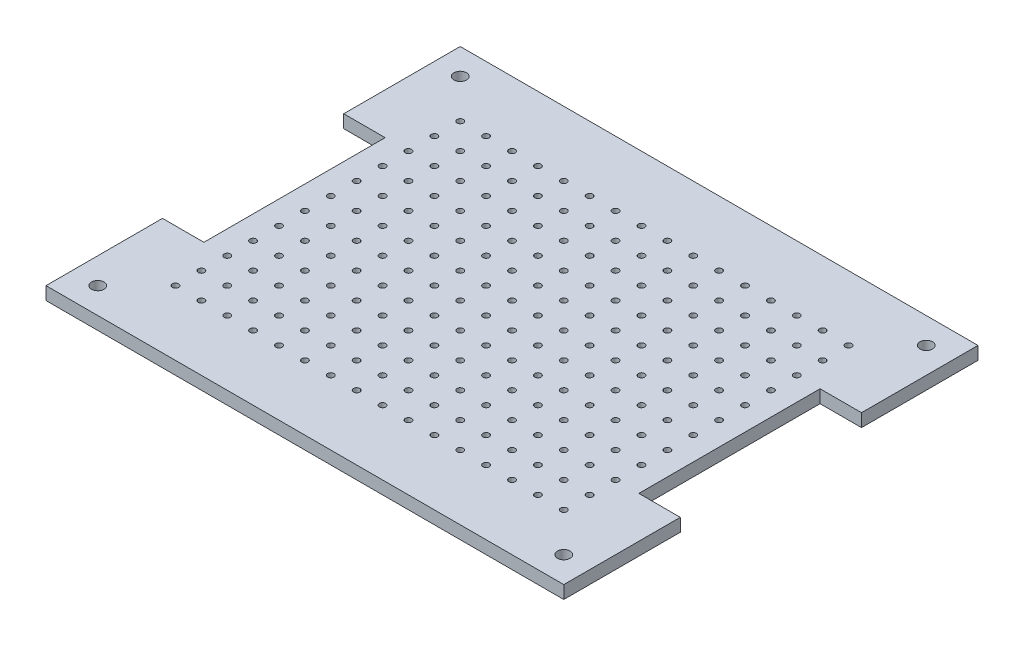
from build123d import *

# Parameters (mm, degrees)
SKETCH1_R           = 1.55
SKETCH1_R_2         = 3.1
BOSS_EXTRUDE1_DEPTH = 6.35


with BuildPart() as part:
    # Sketch1 → Boss-Extrude1 (new body)
    with BuildSketch(Plane(origin=(0, 0, 0), x_dir=(1, 0, 0), z_dir=(0, 1, 0))):
        Polygon((0, 0), (254, 0), (254, 57.15), (233.68, 57.15), (233.68, 146.05), (254, 146.05), (254, 203.2), (0, 203.2), (0, 146.05), (20.32, 146.05), (20.32, 57.15), (0, 57.15), align=None)
        with Locations((31.75, 171.45)):
            Circle(SKETCH1_R, mode=Mode.SUBTRACT)
        with Locations((44.45, 171.45)):
            Circle(SKETCH1_R, mode=Mode.SUBTRACT)
        with Locations((57.15, 171.45)):
            Circle(SKETCH1_R, mode=Mode.SUBTRACT)
        with Locations((69.85, 171.45)):
            Circle(SKETCH1_R, mode=Mode.SUBTRACT)
        with Locations((82.55, 171.45)):
            Circle(SKETCH1_R, mode=Mode.SUBTRACT)
        with Locations((95.25, 171.45)):
            Circle(SKETCH1_R, mode=Mode.SUBTRACT)
        with Locations((107.95, 171.45)):
            Circle(SKETCH1_R, mode=Mode.SUBTRACT)
        with Locations((120.65, 171.45)):
            Circle(SKETCH1_R, mode=Mode.SUBTRACT)
        with Locations((133.35, 171.45)):
            Circle(SKETCH1_R, mode=Mode.SUBTRACT)
        with Locations((146.05, 171.45)):
            Circle(SKETCH1_R, mode=Mode.SUBTRACT)
        with Locations((158.75, 171.45)):
            Circle(SKETCH1_R, mode=Mode.SUBTRACT)
        with Locations((171.45, 171.45)):
            Circle(SKETCH1_R, mode=Mode.SUBTRACT)
        with Locations((184.15, 171.45)):
            Circle(SKETCH1_R, mode=Mode.SUBTRACT)
        with Locations((196.85, 171.45)):
            Circle(SKETCH1_R, mode=Mode.SUBTRACT)
        with Locations((209.55, 171.45)):
            Circle(SKETCH1_R, mode=Mode.SUBTRACT)
        with Locations((222.25, 171.45)):
            Circle(SKETCH1_R, mode=Mode.SUBTRACT)
        with Locations((44.45, 158.75)):
            Circle(SKETCH1_R, mode=Mode.SUBTRACT)
        with Locations((57.15, 158.75)):
            Circle(SKETCH1_R, mode=Mode.SUBTRACT)
        with Locations((69.85, 158.75)):
            Circle(SKETCH1_R, mode=Mode.SUBTRACT)
        with Locations((82.55, 158.75)):
            Circle(SKETCH1_R, mode=Mode.SUBTRACT)
        with Locations((95.25, 158.75)):
            Circle(SKETCH1_R, mode=Mode.SUBTRACT)
        with Locations((107.95, 158.75)):
            Circle(SKETCH1_R, mode=Mode.SUBTRACT)
        with Locations((120.65, 158.75)):
            Circle(SKETCH1_R, mode=Mode.SUBTRACT)
        with Locations((133.35, 158.75)):
            Circle(SKETCH1_R, mode=Mode.SUBTRACT)
        with Locations((146.05, 158.75)):
            Circle(SKETCH1_R, mode=Mode.SUBTRACT)
        with Locations((158.75, 158.75)):
            Circle(SKETCH1_R, mode=Mode.SUBTRACT)
        with Locations((171.45, 158.75)):
            Circle(SKETCH1_R, mode=Mode.SUBTRACT)
        with Locations((184.15, 158.75)):
            Circle(SKETCH1_R, mode=Mode.SUBTRACT)
        with Locations((196.85, 158.75)):
            Circle(SKETCH1_R, mode=Mode.SUBTRACT)
        with Locations((209.55, 158.75)):
            Circle(SKETCH1_R, mode=Mode.SUBTRACT)
        with Locations((222.25, 158.75)):
            Circle(SKETCH1_R, mode=Mode.SUBTRACT)
        with Locations((44.45, 146.05)):
            Circle(SKETCH1_R, mode=Mode.SUBTRACT)
        with Locations((57.15, 146.05)):
            Circle(SKETCH1_R, mode=Mode.SUBTRACT)
        with Locations((69.85, 146.05)):
            Circle(SKETCH1_R, mode=Mode.SUBTRACT)
        with Locations((82.55, 146.05)):
            Circle(SKETCH1_R, mode=Mode.SUBTRACT)
        with Locations((95.25, 146.05)):
            Circle(SKETCH1_R, mode=Mode.SUBTRACT)
        with Locations((107.95, 146.05)):
            Circle(SKETCH1_R, mode=Mode.SUBTRACT)
        with Locations((120.65, 146.05)):
            Circle(SKETCH1_R, mode=Mode.SUBTRACT)
        with Locations((133.35, 146.05)):
            Circle(SKETCH1_R, mode=Mode.SUBTRACT)
        with Locations((146.05, 146.05)):
            Circle(SKETCH1_R, mode=Mode.SUBTRACT)
        with Locations((158.75, 146.05)):
            Circle(SKETCH1_R, mode=Mode.SUBTRACT)
        with Locations((171.45, 146.05)):
            Circle(SKETCH1_R, mode=Mode.SUBTRACT)
        with Locations((184.15, 146.05)):
            Circle(SKETCH1_R, mode=Mode.SUBTRACT)
        with Locations((196.85, 146.05)):
            Circle(SKETCH1_R, mode=Mode.SUBTRACT)
        with Locations((209.55, 146.05)):
            Circle(SKETCH1_R, mode=Mode.SUBTRACT)
        with Locations((222.25, 146.05)):
            Circle(SKETCH1_R, mode=Mode.SUBTRACT)
        with Locations((44.45, 133.35)):
            Circle(SKETCH1_R, mode=Mode.SUBTRACT)
        with Locations((57.15, 133.35)):
            Circle(SKETCH1_R, mode=Mode.SUBTRACT)
        with Locations((69.85, 133.35)):
            Circle(SKETCH1_R, mode=Mode.SUBTRACT)
        with Locations((82.55, 133.35)):
            Circle(SKETCH1_R, mode=Mode.SUBTRACT)
        with Locations((95.25, 133.35)):
            Circle(SKETCH1_R, mode=Mode.SUBTRACT)
        with Locations((107.95, 133.35)):
            Circle(SKETCH1_R, mode=Mode.SUBTRACT)
        with Locations((120.65, 133.35)):
            Circle(SKETCH1_R, mode=Mode.SUBTRACT)
        with Locations((133.35, 133.35)):
            Circle(SKETCH1_R, mode=Mode.SUBTRACT)
        with Locations((146.05, 133.35)):
            Circle(SKETCH1_R, mode=Mode.SUBTRACT)
        with Locations((158.75, 133.35)):
            Circle(SKETCH1_R, mode=Mode.SUBTRACT)
        with Locations((171.45, 133.35)):
            Circle(SKETCH1_R, mode=Mode.SUBTRACT)
        with Locations((184.15, 133.35)):
            Circle(SKETCH1_R, mode=Mode.SUBTRACT)
        with Locations((196.85, 133.35)):
            Circle(SKETCH1_R, mode=Mode.SUBTRACT)
        with Locations((209.55, 133.35)):
            Circle(SKETCH1_R, mode=Mode.SUBTRACT)
        with Locations((222.25, 133.35)):
            Circle(SKETCH1_R, mode=Mode.SUBTRACT)
        with Locations((44.45, 120.65)):
            Circle(SKETCH1_R, mode=Mode.SUBTRACT)
        with Locations((57.15, 120.65)):
            Circle(SKETCH1_R, mode=Mode.SUBTRACT)
        with Locations((69.85, 120.65)):
            Circle(SKETCH1_R, mode=Mode.SUBTRACT)
        with Locations((82.55, 120.65)):
            Circle(SKETCH1_R, mode=Mode.SUBTRACT)
        with Locations((95.25, 120.65)):
            Circle(SKETCH1_R, mode=Mode.SUBTRACT)
        with Locations((107.95, 120.65)):
            Circle(SKETCH1_R, mode=Mode.SUBTRACT)
        with Locations((120.65, 120.65)):
            Circle(SKETCH1_R, mode=Mode.SUBTRACT)
        with Locations((133.35, 120.65)):
            Circle(SKETCH1_R, mode=Mode.SUBTRACT)
        with Locations((146.05, 120.65)):
            Circle(SKETCH1_R, mode=Mode.SUBTRACT)
        with Locations((158.75, 120.65)):
            Circle(SKETCH1_R, mode=Mode.SUBTRACT)
        with Locations((171.45, 120.65)):
            Circle(SKETCH1_R, mode=Mode.SUBTRACT)
        with Locations((184.15, 120.65)):
            Circle(SKETCH1_R, mode=Mode.SUBTRACT)
        with Locations((196.85, 120.65)):
            Circle(SKETCH1_R, mode=Mode.SUBTRACT)
        with Locations((209.55, 120.65)):
            Circle(SKETCH1_R, mode=Mode.SUBTRACT)
        with Locations((222.25, 120.65)):
            Circle(SKETCH1_R, mode=Mode.SUBTRACT)
        with Locations((44.45, 107.95)):
            Circle(SKETCH1_R, mode=Mode.SUBTRACT)
        with Locations((57.15, 107.95)):
            Circle(SKETCH1_R, mode=Mode.SUBTRACT)
        with Locations((69.85, 107.95)):
            Circle(SKETCH1_R, mode=Mode.SUBTRACT)
        with Locations((82.55, 107.95)):
            Circle(SKETCH1_R, mode=Mode.SUBTRACT)
        with Locations((95.25, 107.95)):
            Circle(SKETCH1_R, mode=Mode.SUBTRACT)
        with Locations((107.95, 107.95)):
            Circle(SKETCH1_R, mode=Mode.SUBTRACT)
        with Locations((120.65, 107.95)):
            Circle(SKETCH1_R, mode=Mode.SUBTRACT)
        with Locations((133.35, 107.95)):
            Circle(SKETCH1_R, mode=Mode.SUBTRACT)
        with Locations((146.05, 107.95)):
            Circle(SKETCH1_R, mode=Mode.SUBTRACT)
        with Locations((158.75, 107.95)):
            Circle(SKETCH1_R, mode=Mode.SUBTRACT)
        with Locations((171.45, 107.95)):
            Circle(SKETCH1_R, mode=Mode.SUBTRACT)
        with Locations((184.15, 107.95)):
            Circle(SKETCH1_R, mode=Mode.SUBTRACT)
        with Locations((196.85, 107.95)):
            Circle(SKETCH1_R, mode=Mode.SUBTRACT)
        with Locations((209.55, 107.95)):
            Circle(SKETCH1_R, mode=Mode.SUBTRACT)
        with Locations((222.25, 107.95)):
            Circle(SKETCH1_R, mode=Mode.SUBTRACT)
        with Locations((44.45, 95.25)):
            Circle(SKETCH1_R, mode=Mode.SUBTRACT)
        with Locations((57.15, 95.25)):
            Circle(SKETCH1_R, mode=Mode.SUBTRACT)
        with Locations((69.85, 95.25)):
            Circle(SKETCH1_R, mode=Mode.SUBTRACT)
        with Locations((82.55, 95.25)):
            Circle(SKETCH1_R, mode=Mode.SUBTRACT)
        with Locations((95.25, 95.25)):
            Circle(SKETCH1_R, mode=Mode.SUBTRACT)
        with Locations((107.95, 95.25)):
            Circle(SKETCH1_R, mode=Mode.SUBTRACT)
        with Locations((120.65, 95.25)):
            Circle(SKETCH1_R, mode=Mode.SUBTRACT)
        with Locations((133.35, 95.25)):
            Circle(SKETCH1_R, mode=Mode.SUBTRACT)
        with Locations((146.05, 95.25)):
            Circle(SKETCH1_R, mode=Mode.SUBTRACT)
        with Locations((158.75, 95.25)):
            Circle(SKETCH1_R, mode=Mode.SUBTRACT)
        with Locations((171.45, 95.25)):
            Circle(SKETCH1_R, mode=Mode.SUBTRACT)
        with Locations((184.15, 95.25)):
            Circle(SKETCH1_R, mode=Mode.SUBTRACT)
        with Locations((196.85, 95.25)):
            Circle(SKETCH1_R, mode=Mode.SUBTRACT)
        with Locations((209.55, 95.25)):
            Circle(SKETCH1_R, mode=Mode.SUBTRACT)
        with Locations((222.25, 95.25)):
            Circle(SKETCH1_R, mode=Mode.SUBTRACT)
        with Locations((44.45, 82.55)):
            Circle(SKETCH1_R, mode=Mode.SUBTRACT)
        with Locations((57.15, 82.55)):
            Circle(SKETCH1_R, mode=Mode.SUBTRACT)
        with Locations((69.85, 82.55)):
            Circle(SKETCH1_R, mode=Mode.SUBTRACT)
        with Locations((82.55, 82.55)):
            Circle(SKETCH1_R, mode=Mode.SUBTRACT)
        with Locations((95.25, 82.55)):
            Circle(SKETCH1_R, mode=Mode.SUBTRACT)
        with Locations((107.95, 82.55)):
            Circle(SKETCH1_R, mode=Mode.SUBTRACT)
        with Locations((120.65, 82.55)):
            Circle(SKETCH1_R, mode=Mode.SUBTRACT)
        with Locations((133.35, 82.55)):
            Circle(SKETCH1_R, mode=Mode.SUBTRACT)
        with Locations((146.05, 82.55)):
            Circle(SKETCH1_R, mode=Mode.SUBTRACT)
        with Locations((158.75, 82.55)):
            Circle(SKETCH1_R, mode=Mode.SUBTRACT)
        with Locations((171.45, 82.55)):
            Circle(SKETCH1_R, mode=Mode.SUBTRACT)
        with Locations((184.15, 82.55)):
            Circle(SKETCH1_R, mode=Mode.SUBTRACT)
        with Locations((196.85, 82.55)):
            Circle(SKETCH1_R, mode=Mode.SUBTRACT)
        with Locations((209.55, 82.55)):
            Circle(SKETCH1_R, mode=Mode.SUBTRACT)
        with Locations((222.25, 82.55)):
            Circle(SKETCH1_R, mode=Mode.SUBTRACT)
        with Locations((44.45, 69.85)):
            Circle(SKETCH1_R, mode=Mode.SUBTRACT)
        with Locations((57.15, 69.85)):
            Circle(SKETCH1_R, mode=Mode.SUBTRACT)
        with Locations((69.85, 69.85)):
            Circle(SKETCH1_R, mode=Mode.SUBTRACT)
        with Locations((82.55, 69.85)):
            Circle(SKETCH1_R, mode=Mode.SUBTRACT)
        with Locations((95.25, 69.85)):
            Circle(SKETCH1_R, mode=Mode.SUBTRACT)
        with Locations((107.95, 69.85)):
            Circle(SKETCH1_R, mode=Mode.SUBTRACT)
        with Locations((120.65, 69.85)):
            Circle(SKETCH1_R, mode=Mode.SUBTRACT)
        with Locations((133.35, 69.85)):
            Circle(SKETCH1_R, mode=Mode.SUBTRACT)
        with Locations((146.05, 69.85)):
            Circle(SKETCH1_R, mode=Mode.SUBTRACT)
        with Locations((158.75, 69.85)):
            Circle(SKETCH1_R, mode=Mode.SUBTRACT)
        with Locations((171.45, 69.85)):
            Circle(SKETCH1_R, mode=Mode.SUBTRACT)
        with Locations((184.15, 69.85)):
            Circle(SKETCH1_R, mode=Mode.SUBTRACT)
        with Locations((196.85, 69.85)):
            Circle(SKETCH1_R, mode=Mode.SUBTRACT)
        with Locations((209.55, 69.85)):
            Circle(SKETCH1_R, mode=Mode.SUBTRACT)
        with Locations((222.25, 69.85)):
            Circle(SKETCH1_R, mode=Mode.SUBTRACT)
        with Locations((44.45, 57.15)):
            Circle(SKETCH1_R, mode=Mode.SUBTRACT)
        with Locations((57.15, 57.15)):
            Circle(SKETCH1_R, mode=Mode.SUBTRACT)
        with Locations((69.85, 57.15)):
            Circle(SKETCH1_R, mode=Mode.SUBTRACT)
        with Locations((82.55, 57.15)):
            Circle(SKETCH1_R, mode=Mode.SUBTRACT)
        with Locations((95.25, 57.15)):
            Circle(SKETCH1_R, mode=Mode.SUBTRACT)
        with Locations((107.95, 57.15)):
            Circle(SKETCH1_R, mode=Mode.SUBTRACT)
        with Locations((120.65, 57.15)):
            Circle(SKETCH1_R, mode=Mode.SUBTRACT)
        with Locations((133.35, 57.15)):
            Circle(SKETCH1_R, mode=Mode.SUBTRACT)
        with Locations((146.05, 57.15)):
            Circle(SKETCH1_R, mode=Mode.SUBTRACT)
        with Locations((158.75, 57.15)):
            Circle(SKETCH1_R, mode=Mode.SUBTRACT)
        with Locations((171.45, 57.15)):
            Circle(SKETCH1_R, mode=Mode.SUBTRACT)
        with Locations((184.15, 57.15)):
            Circle(SKETCH1_R, mode=Mode.SUBTRACT)
        with Locations((196.85, 57.15)):
            Circle(SKETCH1_R, mode=Mode.SUBTRACT)
        with Locations((209.55, 57.15)):
            Circle(SKETCH1_R, mode=Mode.SUBTRACT)
        with Locations((222.25, 57.15)):
            Circle(SKETCH1_R, mode=Mode.SUBTRACT)
        with Locations((44.45, 44.45)):
            Circle(SKETCH1_R, mode=Mode.SUBTRACT)
        with Locations((57.15, 44.45)):
            Circle(SKETCH1_R, mode=Mode.SUBTRACT)
        with Locations((69.85, 44.45)):
            Circle(SKETCH1_R, mode=Mode.SUBTRACT)
        with Locations((82.55, 44.45)):
            Circle(SKETCH1_R, mode=Mode.SUBTRACT)
        with Locations((95.25, 44.45)):
            Circle(SKETCH1_R, mode=Mode.SUBTRACT)
        with Locations((107.95, 44.45)):
            Circle(SKETCH1_R, mode=Mode.SUBTRACT)
        with Locations((120.65, 44.45)):
            Circle(SKETCH1_R, mode=Mode.SUBTRACT)
        with Locations((133.35, 44.45)):
            Circle(SKETCH1_R, mode=Mode.SUBTRACT)
        with Locations((146.05, 44.45)):
            Circle(SKETCH1_R, mode=Mode.SUBTRACT)
        with Locations((158.75, 44.45)):
            Circle(SKETCH1_R, mode=Mode.SUBTRACT)
        with Locations((171.45, 44.45)):
            Circle(SKETCH1_R, mode=Mode.SUBTRACT)
        with Locations((184.15, 44.45)):
            Circle(SKETCH1_R, mode=Mode.SUBTRACT)
        with Locations((196.85, 44.45)):
            Circle(SKETCH1_R, mode=Mode.SUBTRACT)
        with Locations((209.55, 44.45)):
            Circle(SKETCH1_R, mode=Mode.SUBTRACT)
        with Locations((222.25, 44.45)):
            Circle(SKETCH1_R, mode=Mode.SUBTRACT)
        with Locations((44.45, 31.75)):
            Circle(SKETCH1_R, mode=Mode.SUBTRACT)
        with Locations((57.15, 31.75)):
            Circle(SKETCH1_R, mode=Mode.SUBTRACT)
        with Locations((69.85, 31.75)):
            Circle(SKETCH1_R, mode=Mode.SUBTRACT)
        with Locations((82.55, 31.75)):
            Circle(SKETCH1_R, mode=Mode.SUBTRACT)
        with Locations((95.25, 31.75)):
            Circle(SKETCH1_R, mode=Mode.SUBTRACT)
        with Locations((107.95, 31.75)):
            Circle(SKETCH1_R, mode=Mode.SUBTRACT)
        with Locations((120.65, 31.75)):
            Circle(SKETCH1_R, mode=Mode.SUBTRACT)
        with Locations((133.35, 31.75)):
            Circle(SKETCH1_R, mode=Mode.SUBTRACT)
        with Locations((146.05, 31.75)):
            Circle(SKETCH1_R, mode=Mode.SUBTRACT)
        with Locations((158.75, 31.75)):
            Circle(SKETCH1_R, mode=Mode.SUBTRACT)
        with Locations((171.45, 31.75)):
            Circle(SKETCH1_R, mode=Mode.SUBTRACT)
        with Locations((184.15, 31.75)):
            Circle(SKETCH1_R, mode=Mode.SUBTRACT)
        with Locations((196.85, 31.75)):
            Circle(SKETCH1_R, mode=Mode.SUBTRACT)
        with Locations((209.55, 31.75)):
            Circle(SKETCH1_R, mode=Mode.SUBTRACT)
        with Locations((222.25, 31.75)):
            Circle(SKETCH1_R, mode=Mode.SUBTRACT)
        with Locations((31.75, 158.75)):
            Circle(SKETCH1_R, mode=Mode.SUBTRACT)
        with Locations((31.75, 146.05)):
            Circle(SKETCH1_R, mode=Mode.SUBTRACT)
        with Locations((31.75, 133.35)):
            Circle(SKETCH1_R, mode=Mode.SUBTRACT)
        with Locations((31.75, 120.65)):
            Circle(SKETCH1_R, mode=Mode.SUBTRACT)
        with Locations((31.75, 107.95)):
            Circle(SKETCH1_R, mode=Mode.SUBTRACT)
        with Locations((31.75, 95.25)):
            Circle(SKETCH1_R, mode=Mode.SUBTRACT)
        with Locations((31.75, 82.55)):
            Circle(SKETCH1_R, mode=Mode.SUBTRACT)
        with Locations((31.75, 69.85)):
            Circle(SKETCH1_R, mode=Mode.SUBTRACT)
        with Locations((31.75, 57.15)):
            Circle(SKETCH1_R, mode=Mode.SUBTRACT)
        with Locations((31.75, 44.45)):
            Circle(SKETCH1_R, mode=Mode.SUBTRACT)
        with Locations((31.75, 31.75)):
            Circle(SKETCH1_R, mode=Mode.SUBTRACT)
        with Locations((12.7, 190.5)):
            Circle(SKETCH1_R_2, mode=Mode.SUBTRACT)
        with Locations((241.3, 190.5)):
            Circle(SKETCH1_R_2, mode=Mode.SUBTRACT)
        with Locations((241.3, 12.7)):
            Circle(SKETCH1_R_2, mode=Mode.SUBTRACT)
        with Locations((12.7, 12.7)):
            Circle(SKETCH1_R_2, mode=Mode.SUBTRACT)
    extrude(amount=BOSS_EXTRUDE1_DEPTH)


solid = part.part
